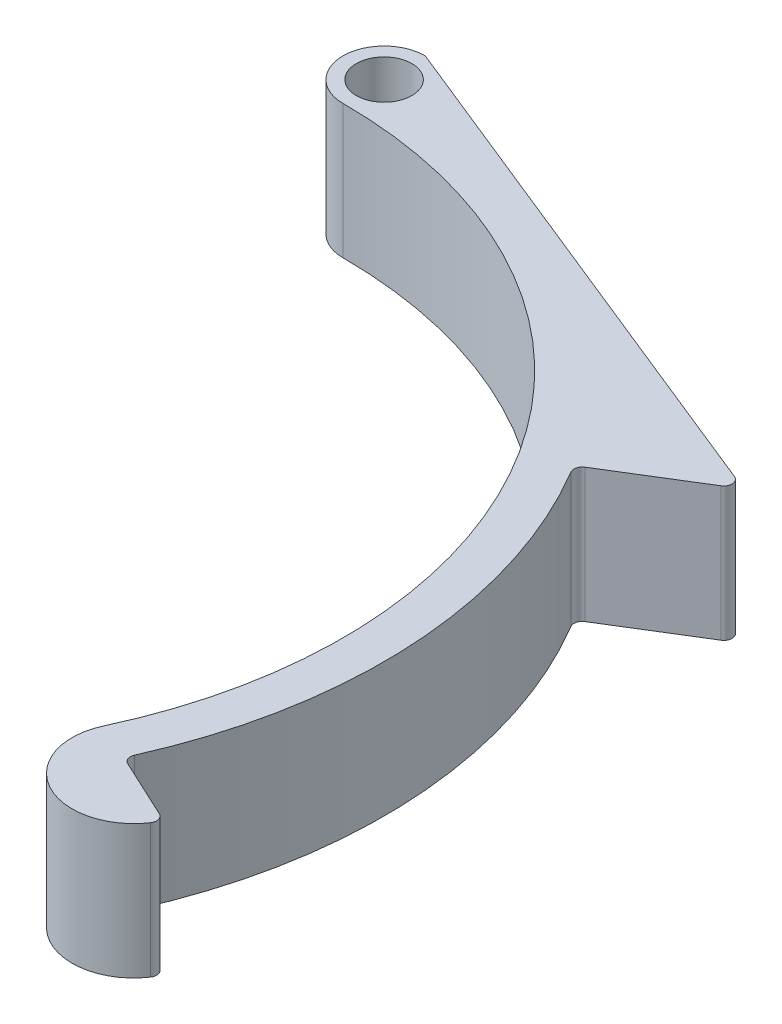
from build123d import *

# Parameters (mm, degrees)
BOSS_EXTRUDE1_DEPTH = 13
FILLET1_R           = 0.8


with BuildPart() as part:
    # Sketch1 → Boss-Extrude1 (new body)
    with BuildSketch(Plane(origin=(0, 0, 0), x_dir=(1, 0, 0), z_dir=(0, 1, 0))):
        with BuildLine():
            Line((0, 51.7), (0, 53))
            ThreePointArc((0, 53), (-4, 49), (0, 45))
            ThreePointArc((0, 45), (37.952615062, 24.178482376), (40.783850417, -19.017821778))
            ThreePointArc((40.783850417, -19.017821778), (43.685987568, -26.991378071), (51.659543861, -24.089240919))
            Line((51.659543861, -24.089240919), (44.409081565, -20.708294825))
            ThreePointArc((44.409081565, -20.708294825), (48.917228757, 2.846880875), (41.707047143, 25.720074234))
            ThreePointArc((41.707047143, 25.720074234), (25.051905135, 42.111780407), (2.698975076, 48.925612245))
            ThreePointArc((2.698975076, 48.925612245), (-1.935309657, 47.117295421), (0, 51.7))
        make_face()
        with BuildLine():
            Line((51.921017872, 32.018867925), (0, 53))
            Line((0, 53), (0, 51.7))
            ThreePointArc((0, 51.7), (1.909188309, 50.909188309), (2.7, 49))
            ThreePointArc((2.7, 49), (2.699743757, 48.962802592), (2.698975076, 48.925612245))
            ThreePointArc((2.698975076, 48.925612245), (25.051905135, 42.111780407), (41.707047143, 25.720074234))
            Line((41.707047143, 25.720074234), (51.921017872, 32.018867925))
        make_face()
    extrude(amount=BOSS_EXTRUDE1_DEPTH)

    # Fillet1
    fillet1_edges = [part.edges().sort_by_distance(p)[0] for p in [
        (0, 6.5, -53),
        (51.921017872, 6.5, -32.018867925),
        (41.707047143, 6.5, -25.720074234),
        (44.409081565, 6.5, 20.708294825),
        (51.659543861, 6.5, 24.089240919),
    ]]
    fillet(fillet1_edges, radius=FILLET1_R)


solid = part.part
